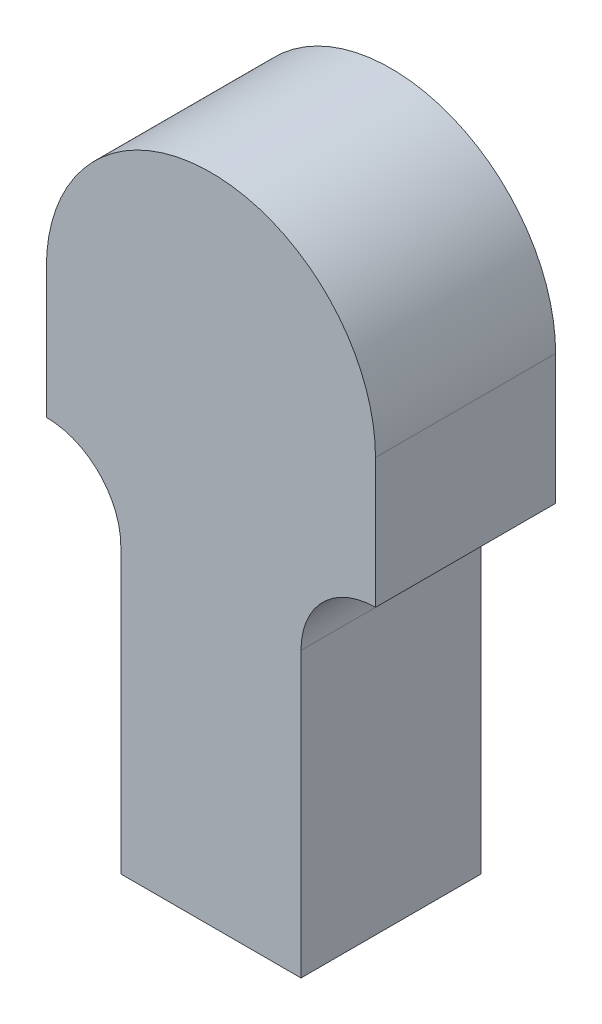
from build123d import *

# Parameters (mm, degrees)
BOSS_EXTRUDE1_DEPTH = 15.875


with BuildPart() as part:
    # Sketch1 → Boss-Extrude1 (new body)
    with BuildSketch(Plane.XY):
        with BuildLine():
            Line((-7.9375, -18), (-7.9375, -43))
            Line((-7.9375, -43), (7.9375, -43))
            Line((7.9375, -43), (7.9375, -18))
            ThreePointArc((7.9375, -18), (9.859611748, -13.359611748), (14.5, -11.4375))
            Line((14.5, -11.4375), (14.5, 0))
            ThreePointArc((14.5, 0), (0, 14.5), (-14.5, 0))
            Line((-14.5, 0), (-14.5, -11.4375))
            ThreePointArc((-14.5, -11.4375), (-9.859611748, -13.359611748), (-7.9375, -18))
        make_face()
    extrude(amount=BOSS_EXTRUDE1_DEPTH)


solid = part.part
